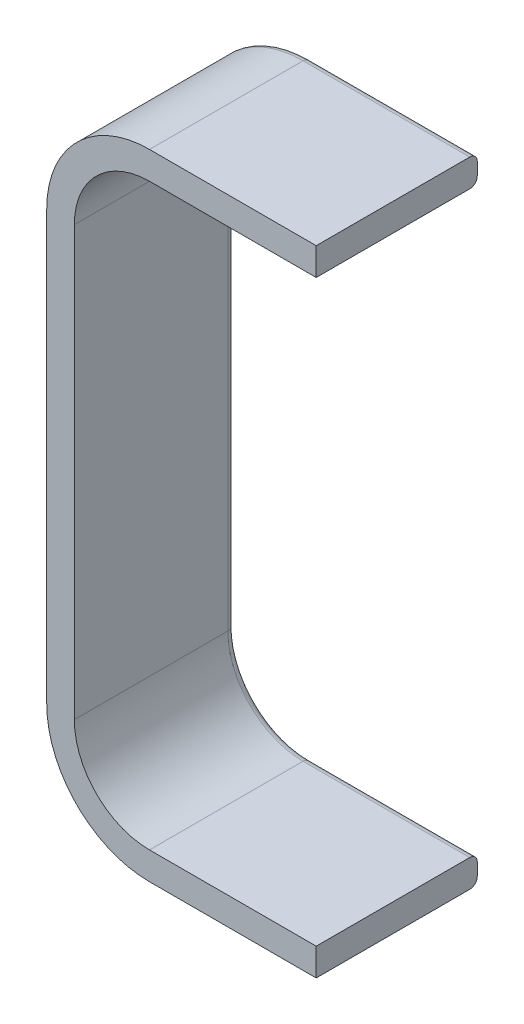
from build123d import *

# Parameters (mm, degrees)
BOSS_EXTRU_1_DEPTH = 128.5
CONG_1_R           = 6


with BuildPart() as part:
    # Esquisse1 → Boss.-Extru.1 (new body)
    with BuildSketch(Plane.XY):
        with BuildLine():
            Line((-133, -22), (0, -22))
            Line((0, -22), (0, 0))
            Line((0, 0), (-133, 0))
            ThreePointArc((-133, 0), (-190.982756057, -24.017243943), (-215, -82))
            Line((-215, -82), (-215, -424))
            ThreePointArc((-215, -424), (-190.982756057, -481.982756057), (-133, -506))
            Line((-133, -506), (0, -506))
            Line((0, -506), (0, -484))
            Line((0, -484), (-133, -484))
            ThreePointArc((-133, -484), (-175.426406871, -466.426406871), (-193, -424))
            Line((-193, -424), (-193, -82))
            ThreePointArc((-193, -82), (-175.426406871, -39.573593129), (-133, -22))
        make_face()
    extrude(amount=-BOSS_EXTRU_1_DEPTH)

    # Congé1
    cong_1_edges = [part.edges().sort_by_distance(p)[0] for p in [
        (-66.5, 0, -128.5),
        (-190.982756057, -24.017243943, -128.5),
        (-215, -253, -128.5),
        (-190.982756057, -481.982756057, -128.5),
        (-66.5, -506, -128.5),
        (-66.5, -484, -128.5),
        (-175.426406871, -466.426406871, -128.5),
        (-193, -253, -128.5),
        (-175.426406871, -39.573593129, -128.5),
        (-66.5, -22, -128.5),
    ]]
    fillet(cong_1_edges, radius=CONG_1_R)


solid = part.part
